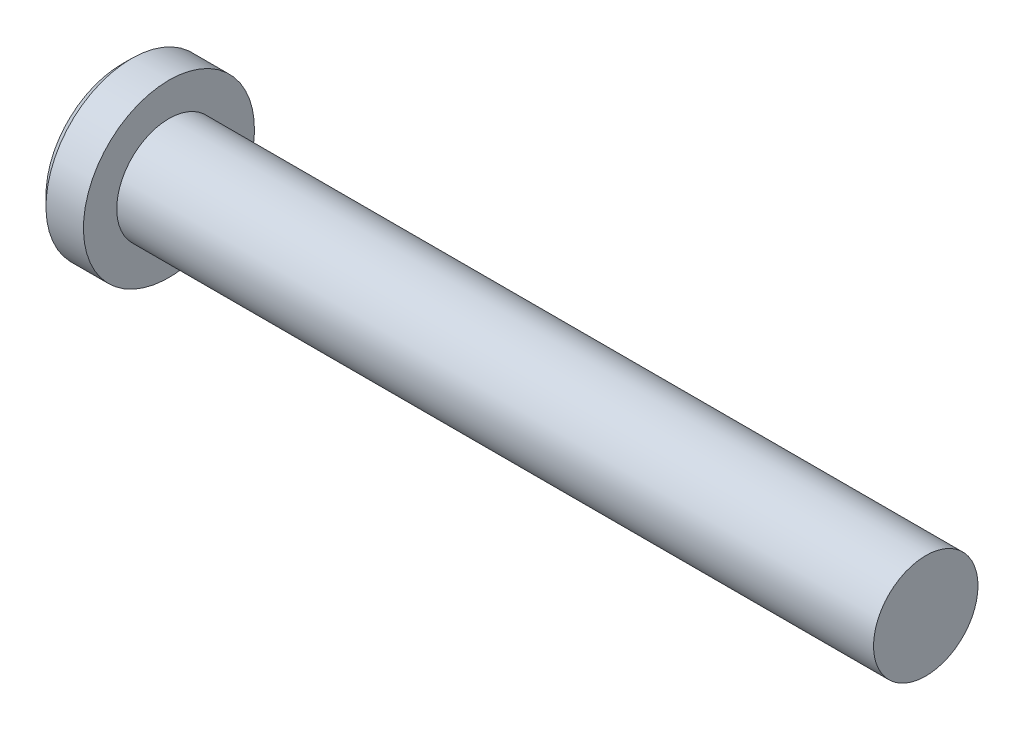
from build123d import *

# Parameters (mm, degrees)
SKETCH2_R           = 1.7526
BOSS_EXTRUDE1_DEPTH = 25.4


with BuildPart() as part:
    # Sketch2 → Boss-Extrude1 (new body)
    with BuildSketch(Plane(origin=(12.7, 0, 0), x_dir=(0, 0, -1), z_dir=(1, 0, 0))):
        Circle(SKETCH2_R)
    extrude(amount=-BOSS_EXTRUDE1_DEPTH)

    # Sketch6 → Revolve1 (revolve)
    with BuildSketch(Plane.XY):
        Polygon((-13.9573, 2.8702), (-14.2875, 2.54), (-14.2875, 0), (-12.7, 0), (-12.7, 2.8702), align=None)
    revolve(axis=Axis((-12.7, 0, 0), (-1, 0, 0)))


solid = part.part
